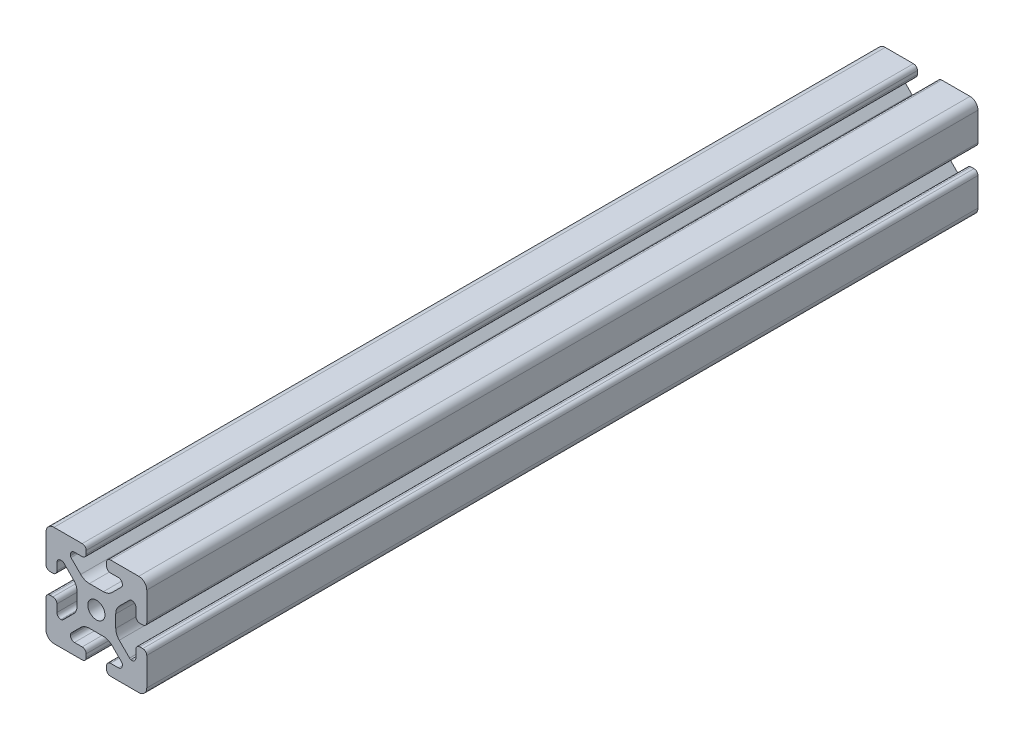
from build123d import *

# Parameters (mm, degrees)
SKETCH1_R      = 3.4
EXTRUDE1_DEPTH = 330


with BuildPart() as part:
    # Sketch1 → Extrude1 (new body)
    with BuildSketch(Plane.XY):
        with BuildLine():
            Line((-8.715, -15.524615034), (-5.63, -15.524615034))
            ThreePointArc((-5.63, -15.524615034), (-4.519842354, -15.984457388), (-4.06, -17.094615034))
            Line((-4.06, -17.094615034), (-4.06, -18.43))
            ThreePointArc((-4.06, -18.43), (-4.519842354, -19.540157646), (-5.63, -20))
            Line((-5.63, -20), (-16.674615034, -20))
            ThreePointArc((-16.674615034, -20), (-18.951578385, -19.194274381), (-20, -17.018368134))
            Line((-20, -17.018368134), (-20, -5.757918808))
            ThreePointArc((-20, -5.757918808), (-19.564709668, -4.603883664), (-18.43, -4.120449326))
            Line((-18.43, -4.120449326), (-17.25, -4.120449326))
            ThreePointArc((-17.25, -4.120449326), (-16.115287682, -4.60388249), (-15.67999625, -5.757919334))
            Line((-15.67999625, -5.757919334), (-15.67999625, -8.715399492))
            ThreePointArc((-15.67999625, -8.715399492), (-15.220153896, -9.825557139), (-14.10999625, -10.285399492))
            Line((-14.10999625, -10.285399492), (-13.816898819, -10.285399492))
            ThreePointArc((-13.816898819, -10.285399492), (-13.526061711, -10.227547119), (-13.279501941, -10.062800646))
            Line((-13.279501941, -10.062800646), (-9.076242789, -5.859541495))
            ThreePointArc((-9.076242789, -5.859541495), (-8.046572221, -4.318530588), (-7.685, -2.500784284))
            Line((-7.685, -2.500784284), (-7.685, 2.500784284))
            ThreePointArc((-7.685, 2.500784284), (-8.046572221, 4.318530588), (-9.076242789, 5.859541495))
            Line((-9.076242789, 5.859541495), (-13.040489136, 9.823787841))
            ThreePointArc((-13.040489136, 9.823787841), (-13.354224618, 10.012729352), (-13.71989919, 10.033001362))
            Line((-13.71989919, 10.033001362), (-14.05520779, 10.044710596))
            ThreePointArc((-14.05520779, 10.044710596), (-15.200613642, 9.605030484), (-15.68, 8.475666998))
            Line((-15.68, 8.475666998), (-15.68, 5.572979049))
            ThreePointArc((-15.68, 5.572979049), (-16.139842354, 4.462821403), (-17.25, 4.002979049))
            Line((-17.25, 4.002979049), (-18.43, 4.002979049))
            ThreePointArc((-18.43, 4.002979049), (-19.540157646, 4.462821403), (-20, 5.572979049))
            Line((-20, 5.572979049), (-20, 13.004526564))
            Line((-20, 13.004526564), (-20, 16.83))
            ThreePointArc((-20, 16.83), (-19.071528496, 19.071528496), (-16.83, 20))
            Line((-16.83, 20), (-5.63, 20))
            ThreePointArc((-5.63, 20), (-4.519842354, 19.540157646), (-4.06, 18.43))
            Line((-4.06, 18.43), (-4.06, 17.094615034))
            ThreePointArc((-4.06, 17.094615034), (-4.519842354, 15.984457388), (-5.63, 15.524615034))
            Line((-5.63, 15.524615034), (-8.715, 15.524615034))
            ThreePointArc((-8.715, 15.524615034), (-9.825157646, 15.06477268), (-10.285, 13.954615034))
            Line((-10.285, 13.954615034), (-10.285, 13.492503602))
            ThreePointArc((-10.285, 13.492503602), (-10.227148445, 13.201664194), (-10.062401154, 12.955102448))
            Line((-10.062401154, 12.955102448), (-6.217092793, 9.109794088))
            ThreePointArc((-6.217092793, 9.109794088), (-4.63891877, 8.055291919), (-2.777335583, 7.685))
            Line((-2.777335583, 7.685), (2.777335583, 7.685))
            ThreePointArc((2.777335583, 7.685), (4.63891877, 8.055291919), (6.217092793, 9.109794088))
            Line((6.217092793, 9.109794088), (10.062401154, 12.955102448))
            ThreePointArc((10.062401154, 12.955102448), (10.227148445, 13.201664194), (10.285, 13.492503602))
            Line((10.285, 13.492503602), (10.285, 13.954615034))
            ThreePointArc((10.285, 13.954615034), (9.825157646, 15.06477268), (8.715, 15.524615034))
            Line((8.715, 15.524615034), (5.63, 15.524615034))
            ThreePointArc((5.63, 15.524615034), (4.519842354, 15.984457388), (4.06, 17.094615034))
            Line((4.06, 17.094615034), (4.06, 18.43))
            ThreePointArc((4.06, 18.43), (4.519842354, 19.540157646), (5.63, 20))
            Line((5.63, 20), (12.979635074, 20))
            Line((12.979635074, 20), (16.83, 20))
            ThreePointArc((16.83, 20), (19.071528496, 19.071528496), (20, 16.83))
            Line((20, 16.83), (20, 13.001098436))
            Line((20, 13.001098436), (20, 5.63))
            ThreePointArc((20, 5.63), (19.540157461, 4.519842693), (18.43, 4.060000526))
            Line((18.43, 4.060000526), (17.24999625, 4.060000526))
            ThreePointArc((17.24999625, 4.060000526), (16.139838603, 4.519842879), (15.67999625, 5.630000526))
            Line((15.67999625, 5.630000526), (15.67999625, 8.715399492))
            ThreePointArc((15.67999625, 8.715399492), (15.220153896, 9.825557139), (14.10999625, 10.285399492))
            Line((14.10999625, 10.285399492), (13.816903094, 10.285399492))
            ThreePointArc((13.816903094, 10.285399492), (13.526063686, 10.227547937), (13.279501941, 10.062800646))
            Line((13.279501941, 10.062800646), (9.076242789, 5.859541495))
            ThreePointArc((9.076242789, 5.859541495), (8.046572221, 4.318530588), (7.685, 2.500784284))
            Line((7.685, 2.500784284), (7.685, -2.500784284))
            ThreePointArc((7.685, -2.500784284), (8.046572221, -4.318530588), (9.076242789, -5.859541495))
            Line((9.076242789, -5.859541495), (13.163657296, -9.946956002))
            ThreePointArc((13.163657296, -9.946956002), (13.35903797, -10.160433474), (13.6200547, -10.285399492))
            Line((13.6200547, -10.285399492), (14.10999625, -10.285399492))
            ThreePointArc((14.10999625, -10.285399492), (15.220153896, -9.825557139), (15.67999625, -8.715399492))
            Line((15.67999625, -8.715399492), (15.67999625, -5.630000526))
            ThreePointArc((15.67999625, -5.630000526), (16.139838603, -4.519842879), (17.24999625, -4.060000526))
            Line((17.24999625, -4.060000526), (18.43, -4.060000526))
            ThreePointArc((18.43, -4.060000526), (19.540157461, -4.519842693), (20, -5.63))
            Line((20, -5.63), (20, -16.83))
            ThreePointArc((20, -16.83), (19.071528496, -19.071528496), (16.83, -20))
            Line((16.83, -20), (13, -20))
            Line((13, -20), (5.63, -20))
            ThreePointArc((5.63, -20), (4.519842354, -19.540157646), (4.06, -18.43))
            Line((4.06, -18.43), (4.06, -17.094615034))
            ThreePointArc((4.06, -17.094615034), (4.519842354, -15.984457388), (5.63, -15.524615034))
            Line((5.63, -15.524615034), (8.715, -15.524615034))
            ThreePointArc((8.715, -15.524615034), (9.825157646, -15.06477268), (10.285, -13.954615034))
            Line((10.285, -13.954615034), (10.285, -13.492503602))
            ThreePointArc((10.285, -13.492503602), (10.227148445, -13.201664194), (10.062401154, -12.955102448))
            Line((10.062401154, -12.955102448), (6.217092793, -9.109794088))
            ThreePointArc((6.217092793, -9.109794088), (4.63891877, -8.055291919), (2.777335583, -7.685))
            Line((2.777335583, -7.685), (-2.777335583, -7.685))
            ThreePointArc((-2.777335583, -7.685), (-4.63891877, -8.055291919), (-6.217092793, -9.109794088))
            Line((-6.217092793, -9.109794088), (-10.062401154, -12.955102448))
            ThreePointArc((-10.062401154, -12.955102448), (-10.227148445, -13.201664194), (-10.285, -13.492503602))
            Line((-10.285, -13.492503602), (-10.285, -13.954615034))
            ThreePointArc((-10.285, -13.954615034), (-9.825157646, -15.06477268), (-8.715, -15.524615034))
        make_face()
        Circle(SKETCH1_R, mode=Mode.SUBTRACT)
    extrude(amount=-EXTRUDE1_DEPTH)


solid = part.part
